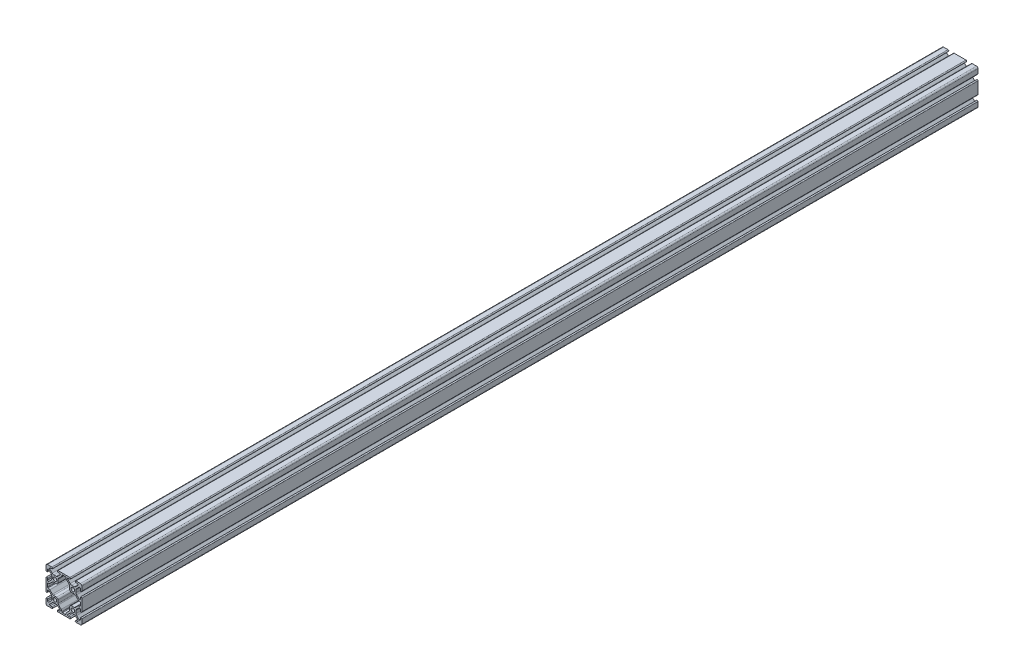
from build123d import *

# Parameters (mm, degrees)
SKETCH1_R           = 2.5
BOSS_EXTRUDE1_DEPTH = 1250


with BuildPart() as part:
    # Sketch1 → Boss-Extrude1 (new body)
    with BuildSketch(Plane(origin=(0, 0, -1500), x_dir=(-1, 0, 0), z_dir=(0, 0, -1))):
        with BuildLine():
            Line((22.86, 8.18), (22.86, 6.071822872))
            ThreePointArc((22.86, 6.071822872), (22.241558145, 5.146259227), (21.149781385, 5.363427127))
            Line((21.149781385, 5.363427127), (17.828471504, 8.684737008))
            ThreePointArc((17.828471504, 8.684737008), (17.141301882, 9.713159024), (16.9, 10.926265504))
            Line((16.9, 10.926265504), (16.9, 14.073734496))
            ThreePointArc((16.9, 14.073734496), (17.141301882, 15.286840976), (17.828471504, 16.315262992))
            Line((17.828471504, 16.315262992), (21.149781385, 19.636572873))
            ThreePointArc((21.149781385, 19.636572873), (22.241558145, 19.853740773), (22.86, 18.928177128))
            Line((22.86, 18.928177128), (22.86, 16.82))
            ThreePointArc((22.86, 16.82), (23.93, 15.75), (25, 16.82))
            Line((25, 16.82), (25, 23))
            ThreePointArc((25, 23), (24.414213562, 24.414213562), (23, 25))
            Line((23, 25), (16.82, 25))
            ThreePointArc((16.82, 25), (15.75, 23.93), (16.82, 22.86))
            Line((16.82, 22.86), (18.928177128, 22.86))
            ThreePointArc((18.928177128, 22.86), (19.853740773, 22.241558145), (19.636572873, 21.149781385))
            Line((19.636572873, 21.149781385), (16.315262992, 17.828471504))
            ThreePointArc((16.315262992, 17.828471504), (15.286840976, 17.141301882), (14.073734496, 16.9))
            Line((14.073734496, 16.9), (10.926265504, 16.9))
            ThreePointArc((10.926265504, 16.9), (9.713159024, 17.141301882), (8.684737008, 17.828471504))
            Line((8.684737008, 17.828471504), (5.363427127, 21.149781385))
            ThreePointArc((5.363427127, 21.149781385), (5.146259227, 22.241558145), (6.071822872, 22.86))
            Line((6.071822872, 22.86), (8.18, 22.86))
            ThreePointArc((8.18, 22.86), (9.25, 23.93), (8.18, 25))
            Line((8.18, 25), (-8.18, 25))
            ThreePointArc((-8.18, 25), (-9.25, 23.93), (-8.18, 22.86))
            Line((-8.18, 22.86), (-6.071822872, 22.86))
            ThreePointArc((-6.071822872, 22.86), (-5.146259227, 22.241558145), (-5.363427127, 21.149781385))
            Line((-5.363427127, 21.149781385), (-8.684737008, 17.828471504))
            ThreePointArc((-8.684737008, 17.828471504), (-9.713159024, 17.141301882), (-10.926265504, 16.9))
            Line((-10.926265504, 16.9), (-14.073734496, 16.9))
            ThreePointArc((-14.073734496, 16.9), (-15.286840976, 17.141301882), (-16.315262992, 17.828471504))
            Line((-16.315262992, 17.828471504), (-19.636572873, 21.149781385))
            ThreePointArc((-19.636572873, 21.149781385), (-19.853740773, 22.241558145), (-18.928177128, 22.86))
            Line((-18.928177128, 22.86), (-16.82, 22.86))
            ThreePointArc((-16.82, 22.86), (-15.75, 23.93), (-16.82, 25))
            Line((-16.82, 25), (-23, 25))
            ThreePointArc((-23, 25), (-24.414213562, 24.414213562), (-25, 23))
            Line((-25, 23), (-25, 16.82))
            ThreePointArc((-25, 16.82), (-23.93, 15.75), (-22.86, 16.82))
            Line((-22.86, 16.82), (-22.86, 18.928177128))
            ThreePointArc((-22.86, 18.928177128), (-22.241558145, 19.853740773), (-21.149781385, 19.636572873))
            Line((-21.149781385, 19.636572873), (-17.828471504, 16.315262992))
            ThreePointArc((-17.828471504, 16.315262992), (-17.141301882, 15.286840976), (-16.9, 14.073734496))
            Line((-16.9, 14.073734496), (-16.9, 10.926265504))
            ThreePointArc((-16.9, 10.926265504), (-17.141301882, 9.713159024), (-17.828471504, 8.684737008))
            Line((-17.828471504, 8.684737008), (-21.149781385, 5.363427127))
            ThreePointArc((-21.149781385, 5.363427127), (-22.241558145, 5.146259227), (-22.86, 6.071822872))
            Line((-22.86, 6.071822872), (-22.86, 8.18))
            ThreePointArc((-22.86, 8.18), (-23.93, 9.25), (-25, 8.18))
            Line((-25, 8.18), (-25, -8.18))
            ThreePointArc((-25, -8.18), (-23.93, -9.25), (-22.86, -8.18))
            Line((-22.86, -8.18), (-22.86, -6.071822872))
            ThreePointArc((-22.86, -6.071822872), (-22.241558145, -5.146259227), (-21.149781385, -5.363427127))
            Line((-21.149781385, -5.363427127), (-17.828471504, -8.684737008))
            ThreePointArc((-17.828471504, -8.684737008), (-17.141301882, -9.713159024), (-16.9, -10.926265504))
            Line((-16.9, -10.926265504), (-16.9, -14.073734496))
            ThreePointArc((-16.9, -14.073734496), (-17.141301882, -15.286840976), (-17.828471504, -16.315262992))
            Line((-17.828471504, -16.315262992), (-21.149781385, -19.636572873))
            ThreePointArc((-21.149781385, -19.636572873), (-22.241558145, -19.853740773), (-22.86, -18.928177128))
            Line((-22.86, -18.928177128), (-22.86, -16.82))
            ThreePointArc((-22.86, -16.82), (-23.93, -15.75), (-25, -16.82))
            Line((-25, -16.82), (-25, -23))
            ThreePointArc((-25, -23), (-24.414213562, -24.414213562), (-23, -25))
            Line((-23, -25), (-16.82, -25))
            ThreePointArc((-16.82, -25), (-15.75, -23.93), (-16.82, -22.86))
            Line((-16.82, -22.86), (-18.928177128, -22.86))
            ThreePointArc((-18.928177128, -22.86), (-19.853740773, -22.241558145), (-19.636572873, -21.149781385))
            Line((-19.636572873, -21.149781385), (-16.315262992, -17.828471504))
            ThreePointArc((-16.315262992, -17.828471504), (-15.286840976, -17.141301882), (-14.073734496, -16.9))
            Line((-14.073734496, -16.9), (-10.926265504, -16.9))
            ThreePointArc((-10.926265504, -16.9), (-9.713159024, -17.141301882), (-8.684737008, -17.828471504))
            Line((-8.684737008, -17.828471504), (-5.363427127, -21.149781385))
            ThreePointArc((-5.363427127, -21.149781385), (-5.146259227, -22.241558145), (-6.071822872, -22.86))
            Line((-6.071822872, -22.86), (-8.18, -22.86))
            ThreePointArc((-8.18, -22.86), (-9.25, -23.93), (-8.18, -25))
            Line((-8.18, -25), (8.18, -25))
            ThreePointArc((8.18, -25), (9.25, -23.93), (8.18, -22.86))
            Line((8.18, -22.86), (6.071822872, -22.86))
            ThreePointArc((6.071822872, -22.86), (5.146259227, -22.241558145), (5.363427127, -21.149781385))
            Line((5.363427127, -21.149781385), (8.684737008, -17.828471504))
            ThreePointArc((8.684737008, -17.828471504), (9.713159024, -17.141301882), (10.926265504, -16.9))
            Line((10.926265504, -16.9), (14.073734496, -16.9))
            ThreePointArc((14.073734496, -16.9), (15.286840976, -17.141301882), (16.315262992, -17.828471504))
            Line((16.315262992, -17.828471504), (19.636572873, -21.149781385))
            ThreePointArc((19.636572873, -21.149781385), (19.853740773, -22.241558145), (18.928177128, -22.86))
            Line((18.928177128, -22.86), (16.82, -22.86))
            ThreePointArc((16.82, -22.86), (15.75, -23.93), (16.82, -25))
            Line((16.82, -25), (23, -25))
            ThreePointArc((23, -25), (24.414213562, -24.414213562), (25, -23))
            Line((25, -23), (25, -16.82))
            ThreePointArc((25, -16.82), (23.93, -15.75), (22.86, -16.82))
            Line((22.86, -16.82), (22.86, -18.928177128))
            ThreePointArc((22.86, -18.928177128), (22.241558145, -19.853740773), (21.149781385, -19.636572873))
            Line((21.149781385, -19.636572873), (17.828471504, -16.315262992))
            ThreePointArc((17.828471504, -16.315262992), (17.141301882, -15.286840976), (16.9, -14.073734496))
            Line((16.9, -14.073734496), (16.9, -10.926265504))
            ThreePointArc((16.9, -10.926265504), (17.141301882, -9.713159024), (17.828471504, -8.684737008))
            Line((17.828471504, -8.684737008), (21.149781385, -5.363427127))
            ThreePointArc((21.149781385, -5.363427127), (22.241558145, -5.146259227), (22.86, -6.071822872))
            Line((22.86, -6.071822872), (22.86, -8.18))
            ThreePointArc((22.86, -8.18), (23.93, -9.25), (25, -8.18))
            Line((25, -8.18), (25, 8.18))
            ThreePointArc((25, 8.18), (23.93, 9.25), (22.86, 8.18))
        make_face()
        with Locations((12.5, 12.5)):
            Circle(SKETCH1_R, mode=Mode.SUBTRACT)
        with Locations((12.5, -12.5)):
            Circle(SKETCH1_R, mode=Mode.SUBTRACT)
        with Locations((-12.5, 12.5)):
            Circle(SKETCH1_R, mode=Mode.SUBTRACT)
        with Locations((-12.5, -12.5)):
            Circle(SKETCH1_R, mode=Mode.SUBTRACT)
        with BuildLine():
            Line((22.86, 2.18156421), (22.86, -2.18156421))
            ThreePointArc((22.86, -2.18156421), (22.637401154, -2.718965364), (22.1, -2.94156421))
            Line((22.1, -2.94156421), (21.85, -2.94156421))
            ThreePointArc((21.85, -2.94156421), (20.644547188, -3.181343683), (19.622613639, -3.864177849))
            Line((19.622613639, -3.864177849), (16.034085502, -7.452705986))
            ThreePointArc((16.034085502, -7.452705986), (15.317109901, -7.931773767), (14.471379515, -8.1))
            Line((14.471379515, -8.1), (10.31, -8.1))
            ThreePointArc((10.31, -8.1), (8.747294014, -8.747294014), (8.1, -10.31))
            Line((8.1, -10.31), (8.1, -14.508658736))
            ThreePointArc((8.1, -14.508658736), (7.938624609, -15.319947613), (7.479066376, -16.007725112))
            Line((7.479066376, -16.007725112), (3.850249953, -19.636541535))
            ThreePointArc((3.850249953, -19.636541535), (3.169188366, -20.655822232), (2.93003134, -21.858145792))
            Line((2.93003134, -21.858145792), (2.93003134, -22.1))
            ThreePointArc((2.93003134, -22.1), (2.707432494, -22.637401154), (2.17003134, -22.86))
            Line((2.17003134, -22.86), (-2.17003134, -22.86))
            ThreePointArc((-2.17003134, -22.86), (-2.707432494, -22.637401154), (-2.93003134, -22.1))
            Line((-2.93003134, -22.1), (-2.93003134, -21.858145792))
            ThreePointArc((-2.93003134, -21.858145792), (-3.169188366, -20.655822232), (-3.850249953, -19.636541535))
            Line((-3.850249953, -19.636541535), (-7.479066376, -16.007725112))
            ThreePointArc((-7.479066376, -16.007725112), (-7.938624609, -15.319947613), (-8.1, -14.508658736))
            Line((-8.1, -14.508658736), (-8.1, -10.31))
            ThreePointArc((-8.1, -10.31), (-8.747294014, -8.747294014), (-10.31, -8.1))
            Line((-10.31, -8.1), (-14.471379515, -8.1))
            ThreePointArc((-14.471379515, -8.1), (-15.317109901, -7.931773767), (-16.034085502, -7.452705986))
            Line((-16.034085502, -7.452705986), (-19.622613639, -3.864177849))
            ThreePointArc((-19.622613639, -3.864177849), (-20.644547188, -3.181343683), (-21.85, -2.94156421))
            Line((-21.85, -2.94156421), (-22.1, -2.94156421))
            ThreePointArc((-22.1, -2.94156421), (-22.637401154, -2.718965364), (-22.86, -2.18156421))
            Line((-22.86, -2.18156421), (-22.86, 2.18156421))
            ThreePointArc((-22.86, 2.18156421), (-22.637401154, 2.718965364), (-22.1, 2.94156421))
            Line((-22.1, 2.94156421), (-21.85, 2.94156421))
            ThreePointArc((-21.85, 2.94156421), (-20.644547188, 3.181343683), (-19.622613639, 3.864177849))
            Line((-19.622613639, 3.864177849), (-16.034085502, 7.452705986))
            ThreePointArc((-16.034085502, 7.452705986), (-15.317109901, 7.931773767), (-14.471379515, 8.1))
            Line((-14.471379515, 8.1), (-10.31, 8.1))
            ThreePointArc((-10.31, 8.1), (-8.747294014, 8.747294014), (-8.1, 10.31))
            Line((-8.1, 10.31), (-8.1, 14.508658736))
            ThreePointArc((-8.1, 14.508658736), (-7.938624609, 15.319947613), (-7.479066376, 16.007725112))
            Line((-7.479066376, 16.007725112), (-3.850249953, 19.636541535))
            ThreePointArc((-3.850249953, 19.636541535), (-3.169188366, 20.655822232), (-2.93003134, 21.858145792))
            Line((-2.93003134, 21.858145792), (-2.93003134, 22.1))
            ThreePointArc((-2.93003134, 22.1), (-2.707432494, 22.637401154), (-2.17003134, 22.86))
            Line((-2.17003134, 22.86), (2.17003134, 22.86))
            ThreePointArc((2.17003134, 22.86), (2.707432494, 22.637401154), (2.93003134, 22.1))
            Line((2.93003134, 22.1), (2.93003134, 21.858145792))
            ThreePointArc((2.93003134, 21.858145792), (3.169188366, 20.655822232), (3.850249953, 19.636541535))
            Line((3.850249953, 19.636541535), (7.479066376, 16.007725112))
            ThreePointArc((7.479066376, 16.007725112), (7.938624609, 15.319947613), (8.1, 14.508658736))
            Line((8.1, 14.508658736), (8.1, 10.31))
            ThreePointArc((8.1, 10.31), (8.747294014, 8.747294014), (10.31, 8.1))
            Line((10.31, 8.1), (14.471379515, 8.1))
            ThreePointArc((14.471379515, 8.1), (15.317109901, 7.931773767), (16.034085502, 7.452705986))
            Line((16.034085502, 7.452705986), (19.622613639, 3.864177849))
            ThreePointArc((19.622613639, 3.864177849), (20.644547188, 3.181343683), (21.85, 2.94156421))
            Line((21.85, 2.94156421), (22.1, 2.94156421))
            ThreePointArc((22.1, 2.94156421), (22.637401154, 2.718965364), (22.86, 2.18156421))
        make_face(mode=Mode.SUBTRACT)
    extrude(amount=-BOSS_EXTRUDE1_DEPTH)


solid = part.part
